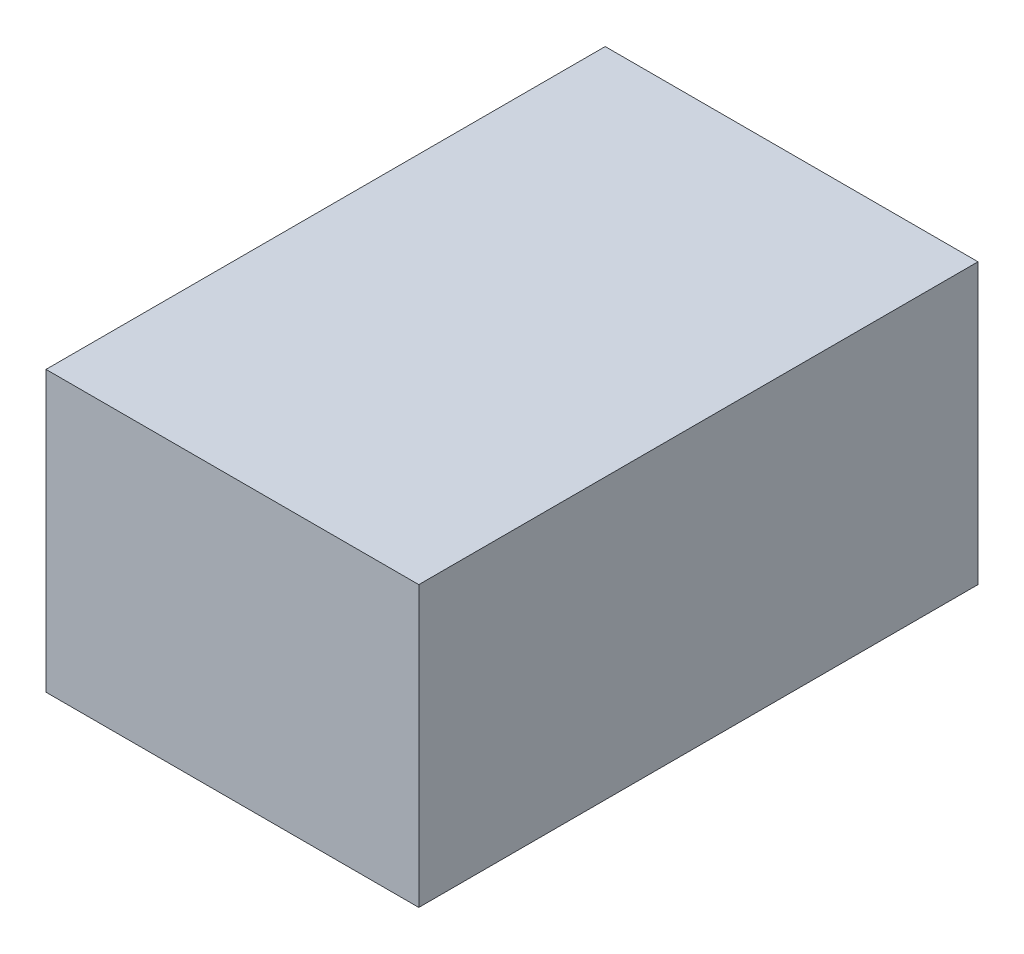
from build123d import *

# Parameters (mm, degrees)
SKETCH1_W           = 101.6
SKETCH1_H           = 76.2
BOSS_EXTRUDE1_DEPTH = 152.4


with BuildPart() as part:
    # Sketch1 → Boss-Extrude1 (new body)
    with BuildSketch(Plane.XY):
        with Locations((50.8, 38.1)):
            Rectangle(SKETCH1_W, SKETCH1_H)
    extrude(amount=BOSS_EXTRUDE1_DEPTH)


solid = part.part
